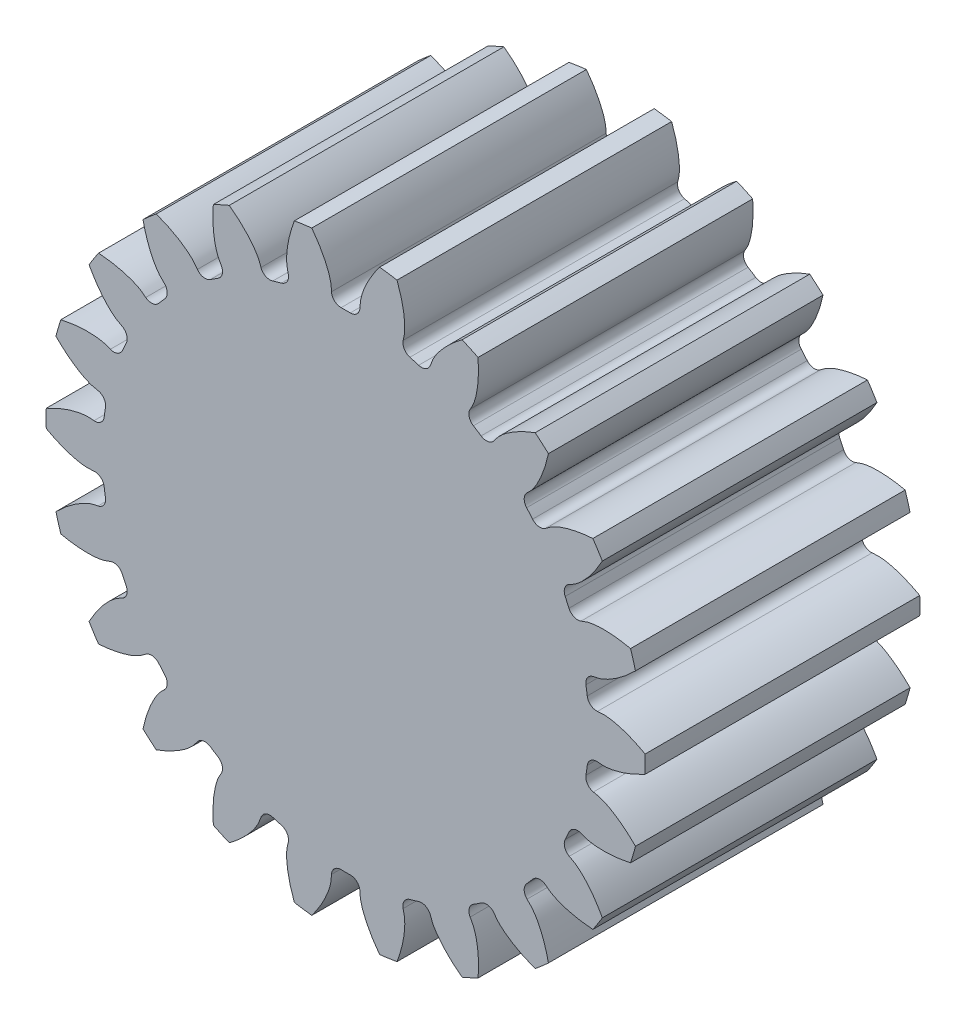
from build123d import *

# Parameters (mm, degrees)
SKETCH_1_R          = 12
LASHENA_DEPTH       = 11
CUT_EXTRUDEA_DEPTH  = 11
WWW_KYTOOL_CN_COUNT = 22


with BuildPart() as part:
    # 草图1 → LaShenA (new body)
    with BuildSketch(Plane.XY):
        Circle(SKETCH_1_R)
    extrude(amount=LASHENA_DEPTH)

    # SketchA → Cut-ExtrudeA (cut)
    with BuildSketch(Plane.XY.offset(11)):
        with BuildLine():
            ThreePointArc((0.182879362, 9.748284728), (0, 9.75), (-0.182879362, 9.748284728))
            ThreePointArc((-0.182879362, 9.748284728), (-0.448060073, 9.849275956), (-0.569345731, 10.105810216))
            add(Edge.make_bspline(
                [(-0.569345731, 10.105810216), (-0.573591107, 10.177680095), (-0.577643596, 10.279301189), (-0.593745042, 10.393872889), (-0.605991459, 10.452320563), (-0.616818624, 10.498614976), (-0.630770308, 10.551669694), (-0.648153589, 10.611362458), (-0.669349266, 10.677537989), (-0.694706721, 10.750032499), (-0.724577307, 10.82866601), (-0.759303081, 10.913245071), (-0.799219658, 11.003562214), (-0.84465469, 11.099396443), (-0.895927694, 11.200513431), (-0.953349478, 11.306665825), (-1.017221714, 11.417593537), (-1.08783646, 11.533024063), (-1.165475733, 11.652672813), (-1.250411053, 11.776243453), (-1.342903064, 11.903428265), (-1.443200981, 12.03390853), (-1.590730176, 12.21562271), (-1.709283, 12.3500743), (-1.792204576, 12.439417704)],
                knots=[0.122554338, 0.122554338, 0.122554338, 0.122554338, 0.19270508, 0.222547384, 0.235684065, 0.251209233, 0.269122888, 0.289425031, 0.31211566, 0.337194777, 0.364662381, 0.394518473, 0.426763051, 0.461396117, 0.49841767, 0.537827711, 0.579626238, 0.623813253, 0.670388755, 0.719352744, 0.770705221, 0.824446185, 0.880575636, 1, 1, 1, 1], degree=3))
            ThreePointArc((-1.792204576, 12.439417704), (0, 12.567860202), (1.792204576, 12.439417704))
            add(Edge.make_bspline(
                [(0.569345731, 10.105810216), (0.573591107, 10.177680095), (0.577643596, 10.279301189), (0.593745042, 10.393872889), (0.605991459, 10.452320563), (0.616818624, 10.498614976), (0.630770308, 10.551669694), (0.648153589, 10.611362458), (0.669349266, 10.677537989), (0.694706721, 10.750032499), (0.724577307, 10.82866601), (0.759303081, 10.913245071), (0.799219658, 11.003562214), (0.84465469, 11.099396443), (0.895927694, 11.200513431), (0.953349478, 11.306665825), (1.017221714, 11.417593537), (1.08783646, 11.533024063), (1.165475733, 11.652672813), (1.250411053, 11.776243453), (1.342903064, 11.903428265), (1.443200981, 12.03390853), (1.590730176, 12.21562271), (1.709283, 12.3500743), (1.792204576, 12.439417704)],
                knots=[0.122554338, 0.122554338, 0.122554338, 0.122554338, 0.19270508, 0.222547384, 0.235684065, 0.251209233, 0.269122888, 0.289425031, 0.31211566, 0.337194777, 0.364662381, 0.394518473, 0.426763051, 0.461396117, 0.49841767, 0.537827711, 0.579626238, 0.623813253, 0.670388755, 0.719352744, 0.770705221, 0.824446185, 0.880575636, 1, 1, 1, 1], degree=3))
            ThreePointArc((0.569345731, 10.105810216), (0.448060073, 9.849275956), (0.182879362, 9.748284728))
        make_face()
    cut_extrudea = extrude(amount=-CUT_EXTRUDEA_DEPTH, mode=Mode.SUBTRACT)

    # www.KYTool.cn: Cut-ExtrudeA ×22 about axis
    www_kytool_cn_axis = Axis((0, 0, -88.99), (0, 0, 1))
    for i in range(1, WWW_KYTOOL_CN_COUNT):
        add(cut_extrudea.rotate(www_kytool_cn_axis, i * 360 / WWW_KYTOOL_CN_COUNT), mode=Mode.SUBTRACT)


solid = part.part
